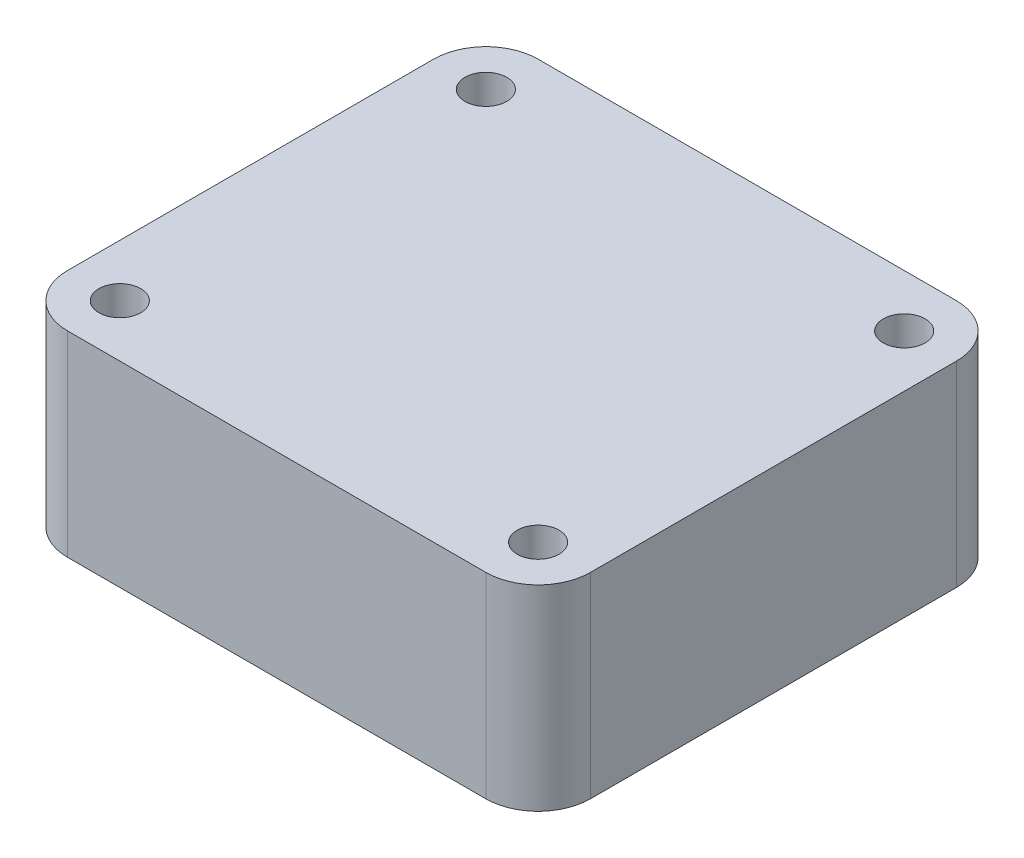
from build123d import *

# Parameters (mm, degrees)
SKETCH1_R           = 1.6
BOSS_EXTRUDE1_DEPTH = 15


with BuildPart() as part:
    # Sketch1 → Boss-Extrude1 (new body)
    with BuildSketch(Plane(origin=(0, 0, 0), x_dir=(1, 0, 0), z_dir=(0, 1, 0))):
        with BuildLine():
            Line((-16, -18), (16, -18))
            ThreePointArc((16, -18), (18.828427125, -16.828427125), (20, -14))
            Line((20, -14), (20, 14))
            ThreePointArc((20, 14), (18.828427125, 16.828427125), (16, 18))
            Line((16, 18), (-16, 18))
            ThreePointArc((-16, 18), (-18.828427125, 16.828427125), (-20, 14))
            Line((-20, 14), (-20, -14))
            ThreePointArc((-20, -14), (-18.828427125, -16.828427125), (-16, -18))
        make_face()
        with Locations((16, 14)):
            Circle(SKETCH1_R, mode=Mode.SUBTRACT)
        with Locations((-16, 14)):
            Circle(SKETCH1_R, mode=Mode.SUBTRACT)
        with Locations((-16, -14)):
            Circle(SKETCH1_R, mode=Mode.SUBTRACT)
        with Locations((16, -14)):
            Circle(SKETCH1_R, mode=Mode.SUBTRACT)
    extrude(amount=BOSS_EXTRUDE1_DEPTH)


solid = part.part
